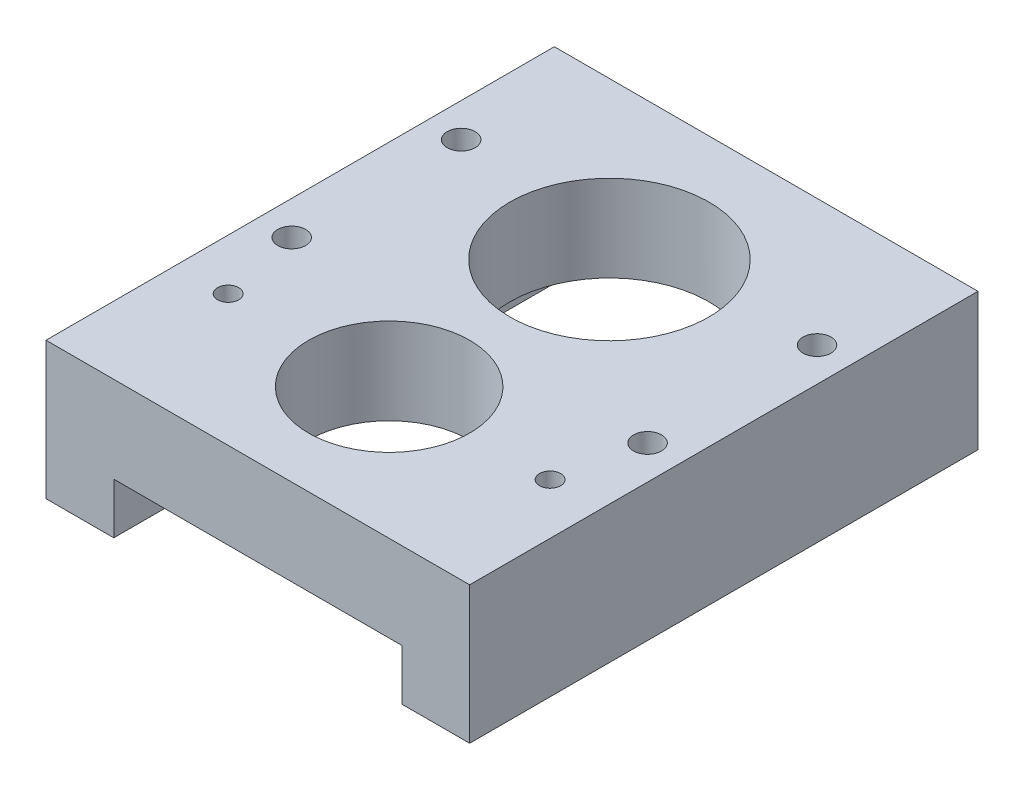
from build123d import *

# Parameters (mm, degrees)
EXTRUDE_1_DEPTH     = 60
SKETCH_2_R          = 11.75
CUT_EXTRUDE_1_DEPTH = 40
SKETCH_3_R          = 9.5
CUT_EXTRUDE_2_DEPTH = 40
M3X0_5_1_D          = 2.5
M3X0_5_1_DEPTH      = 5
M3X0_5_1_TIP        = 0.751075774
CUT_EXTRUDE_3_REACH = 18.2
SKETCH_7_R          = 1.65


with BuildPart() as part:
    # 草圖1 → 填料-伸長1 (new body)
    with BuildSketch(Plane.XY):
        Polygon((-25, 0), (-17, 0), (-17, 6), (17, 6), (17, 0), (25, 0), (25, 16.2), (-25, 16.2), align=None)
    extrude(amount=EXTRUDE_1_DEPTH)

    # 草圖2 → 除料-伸長1 (cut)
    with BuildSketch(Plane(origin=(0, 16.2, 0), x_dir=(1, 0, 0), z_dir=(0, 1, 0))):
        with Locations((0, -18.5)):
            Circle(SKETCH_2_R)
    extrude(amount=-CUT_EXTRUDE_1_DEPTH, mode=Mode.SUBTRACT)

    # 草圖3 → 除料-伸長2 (cut)
    with BuildSketch(Plane(origin=(0, 16.2, 0), x_dir=(1, 0, 0), z_dir=(0, 1, 0))):
        with Locations((0, -44.5)):
            Circle(SKETCH_3_R)
    extrude(amount=-CUT_EXTRUDE_2_DEPTH, mode=Mode.SUBTRACT)

    # M3x0.5 螺紋孔1
    with Locations(Plane(origin=(0, 16.2, 0), x_dir=(1, 0, 0), z_dir=(0, 1, 0))):
        with Locations((19, -44.5), (-19, -44.5)):
            Hole(M3X0_5_1_D / 2, depth=M3X0_5_1_DEPTH)
            with Locations((0, 0, -(M3X0_5_1_DEPTH + M3X0_5_1_TIP / 2))):  # 118° drill point
                Cone(0, M3X0_5_1_D / 2, M3X0_5_1_TIP, mode=Mode.SUBTRACT)

    # 草圖7 → 除料-伸長3 (cut, up to next)
    with BuildSketch(Plane(origin=(0, 16.2, 0), x_dir=(1, 0, 0), z_dir=(0, 1, 0)), mode=Mode.PRIVATE) as cut_extrude_3_sk1:
        with Locations((-21, -35)):
            Circle(SKETCH_7_R)
    cut_extrude_3_tool1 = extrude(cut_extrude_3_sk1.sketch, amount=-CUT_EXTRUDE_3_REACH, mode=Mode.PRIVATE) & part.part
    add(cut_extrude_3_tool1.solids().sort_by_distance((-21, 16.2, 35))[0], mode=Mode.SUBTRACT)
    # 草圖7 → 除料-伸長3 (cut, up to next)
    with BuildSketch(Plane(origin=(0, 16.2, 0), x_dir=(1, 0, 0), z_dir=(0, 1, 0)), mode=Mode.PRIVATE) as cut_extrude_3_sk2:
        with Locations((-21, -15)):
            Circle(SKETCH_7_R)
    cut_extrude_3_tool2 = extrude(cut_extrude_3_sk2.sketch, amount=-CUT_EXTRUDE_3_REACH, mode=Mode.PRIVATE) & part.part
    add(cut_extrude_3_tool2.solids().sort_by_distance((-21, 16.2, 15))[0], mode=Mode.SUBTRACT)
    # 草圖7 → 除料-伸長3 (cut, up to next)
    with BuildSketch(Plane(origin=(0, 16.2, 0), x_dir=(1, 0, 0), z_dir=(0, 1, 0)), mode=Mode.PRIVATE) as cut_extrude_3_sk3:
        with Locations((21, -35)):
            Circle(SKETCH_7_R)
    cut_extrude_3_tool3 = extrude(cut_extrude_3_sk3.sketch, amount=-CUT_EXTRUDE_3_REACH, mode=Mode.PRIVATE) & part.part
    add(cut_extrude_3_tool3.solids().sort_by_distance((21, 16.2, 35))[0], mode=Mode.SUBTRACT)
    # 草圖7 → 除料-伸長3 (cut, up to next)
    with BuildSketch(Plane(origin=(0, 16.2, 0), x_dir=(1, 0, 0), z_dir=(0, 1, 0)), mode=Mode.PRIVATE) as cut_extrude_3_sk4:
        with Locations((21, -15)):
            Circle(SKETCH_7_R)
    cut_extrude_3_tool4 = extrude(cut_extrude_3_sk4.sketch, amount=-CUT_EXTRUDE_3_REACH, mode=Mode.PRIVATE) & part.part
    add(cut_extrude_3_tool4.solids().sort_by_distance((21, 16.2, 15))[0], mode=Mode.SUBTRACT)


solid = part.part
